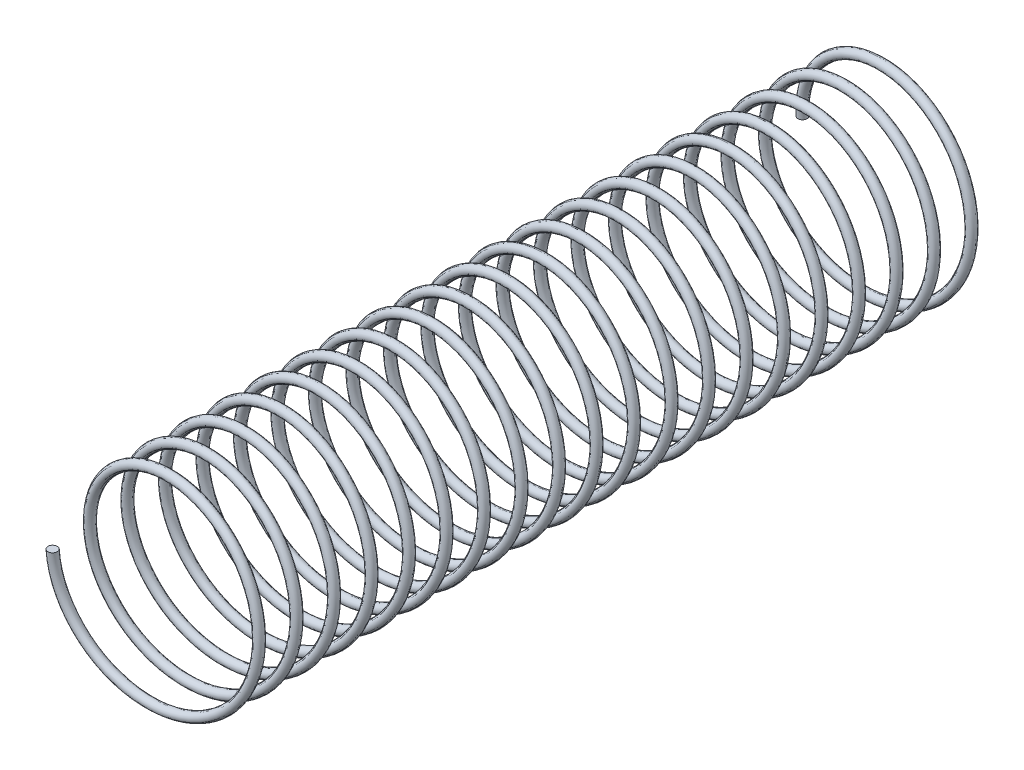
from build123d import *

# Parameters (mm, degrees)
SWEEP1_PITCH       = 1.27
SWEEP1_HEIGHT      = 25.4
SWEEP1_RADIUS      = 3.175
SWEEP1_START_ANGLE = -180
SKETCH2_R          = 0.15875


with BuildPart() as part:
    # Sweep1: sweep along a helix
    with BuildLine() as sweep1_path:
        add(Helix(SWEEP1_PITCH, SWEEP1_HEIGHT, SWEEP1_RADIUS, center=(0, 0, 0), direction=(0, 0, 1), lefthand=True, mode=Mode.PRIVATE).rotate(Axis((0, 0, 0), (0, 0, 1)), SWEEP1_START_ANGLE))
    # Sketch2 → Sweep1 (sweep)
    with BuildSketch(Plane(origin=(0, 0, 0), x_dir=(1, 0, 0), z_dir=(0, 1, 0))):
        with Locations((-3.175, 0)):
            Circle(SKETCH2_R)
    sweep(path=sweep1_path.line, is_frenet=True)


solid = part.part
